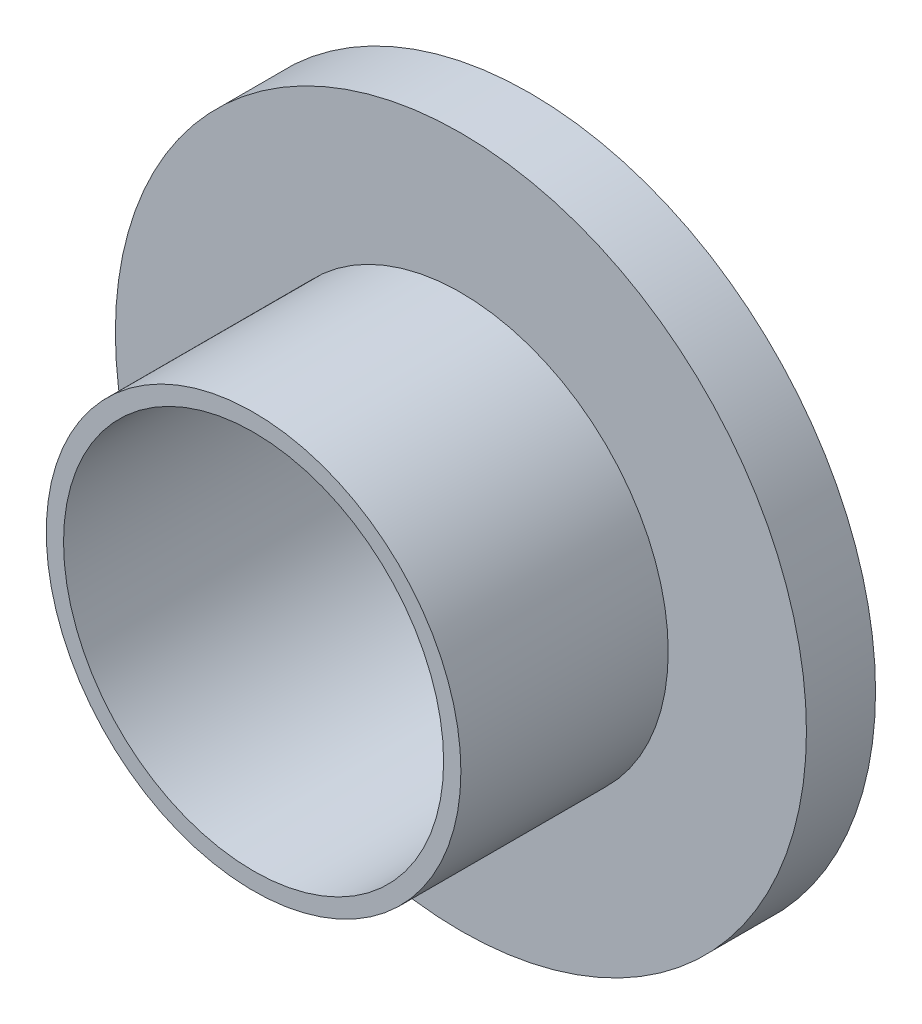
from build123d import *

# Parameters (mm, degrees)
ESQUISSE1_R             = 20
BOSS_EXTRU_1_DEPTH      = 16
ESQUISSE2_R             = 20
ESQUISSE2_R_2           = 12
ENL_V_MAT_EXTRU_1_DEPTH = 12
ESQUISSE3_R             = 11
ENL_V_MAT_EXTRU_2_DEPTH = 17


with BuildPart() as part:
    # Esquisse1 → Boss.-Extru.1 (new body)
    with BuildSketch(Plane.XY):
        Circle(ESQUISSE1_R)
    extrude(amount=BOSS_EXTRU_1_DEPTH)

    # Esquisse2 → Enlèv. mat.-Extru.1 (cut)
    with BuildSketch(Plane.XY.offset(16)):
        Circle(ESQUISSE2_R)
        Circle(ESQUISSE2_R_2, mode=Mode.SUBTRACT)
    extrude(amount=-ENL_V_MAT_EXTRU_1_DEPTH, mode=Mode.SUBTRACT)

    # Esquisse3 → Enlèv. mat.-Extru.2 (cut, through all)
    with BuildSketch(Plane.XY.offset(16)):
        Circle(ESQUISSE3_R)
    extrude(amount=-ENL_V_MAT_EXTRU_2_DEPTH, mode=Mode.SUBTRACT)


solid = part.part
